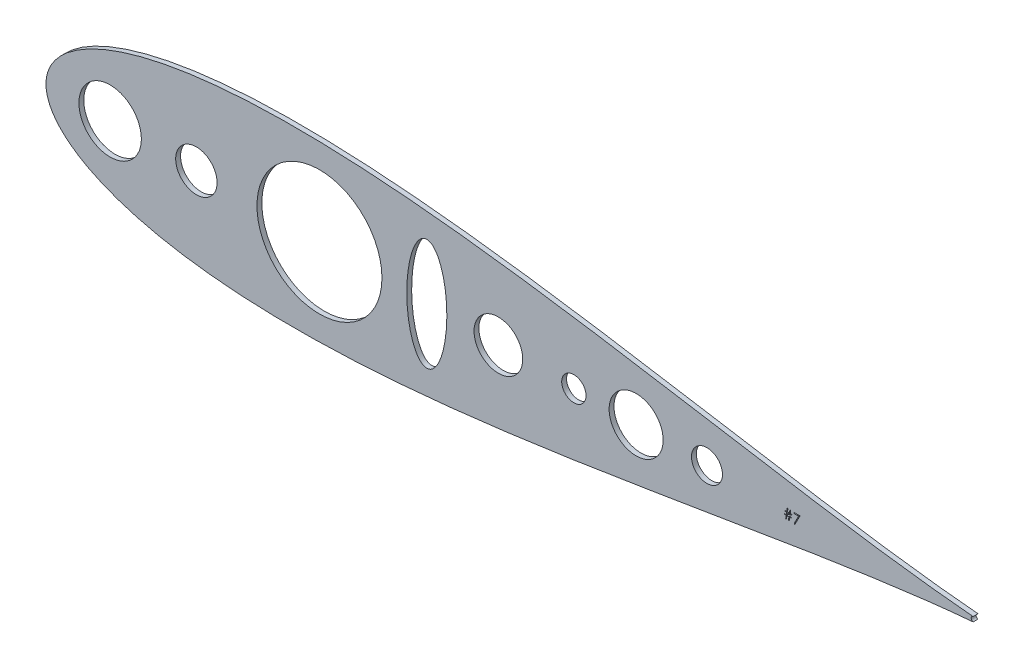
from build123d import *

# Parameters (mm, degrees)
SKETCH2_R           = 16.284851911
SKETCH2_R_2         = 8.086464582
SKETCH2_R_3         = 14.095693802
SKETCH2_R_4         = 6.35
SKETCH2_R_5         = 12.7
SKETCH2_R_6         = 32.589606416
SKETCH2_R_7         = 10.795
SKETCH2_RX          = 29.101247041
SKETCH2_RY          = 10.44471683
BOSS_EXTRUDE1_DEPTH = 2.54


with BuildPart() as part:
    # Sketch2 → Boss-Extrude1 (new body)
    with BuildSketch(Plane.XY):
        with BuildLine():
            ThreePointArc((405.057409883, 1.219307274), (404.060332019, 0.001097472), (405.054413981, -1.219558271))
            add(Edge.make_bspline(
                [(405.057409883, 1.219307274), (404.779756403, 1.242568099), (401.955826011, 1.481310599), (396.284184548, 2.00552928), (387.700215517, 2.898488012), (378.182946349, 3.994235028), (367.768153654, 5.299339088), (356.504426933, 6.815129022), (344.440475863, 8.538206481), (331.628541709, 10.45967103), (318.123030174, 12.56585373), (303.980521449, 14.837949085), (289.259460847, 17.252489472), (274.019988904, 19.781638356), (258.323746519, 22.393472599), (242.233771661, 25.052554066), (225.814395691, 27.720355074), (209.13118913, 30.355889946), (192.250926116, 32.91626741), (175.241581744, 35.357451938), (158.172324108, 37.634822456), (141.113531081, 39.703967669), (124.136802012, 41.521324365), (107.314968663, 43.044946686), (90.722088255, 44.235118014), (74.433442027, 45.055093643), (58.525518859, 45.471792128), (43.075989256, 45.45632188), (28.163731472, 44.984141559), (13.868832743, 44.036763855), (0.27282201, 42.600450864), (-12.541200968, 40.668728208), (-24.48778885, 38.240918261), (-35.478566578, 35.325144932), (-45.42061789, 31.938496856), (-54.214761136, 28.111149637), (-61.754202147, 23.893785873), (-67.926305087, 19.371988319), (-72.627138784, 14.69344535), (-75.809678334, 10.105526882), (-77.58435108, 5.966312248), (-78.30099748, 2.645888854), (-78.464220154, 3e-09), (-78.30099748, -2.645888848), (-77.58435108, -5.966312241), (-75.809678334, -10.105526876), (-72.627138784, -14.693445344), (-67.926305087, -19.371988313), (-61.754202147, -23.893785867), (-54.214761136, -28.11114963), (-45.42061789, -31.938496849), (-35.478566578, -35.325144925), (-24.48778885, -38.240918255), (-12.541200968, -40.668728202), (0.27282201, -42.600450858), (13.868832743, -44.036763849), (28.163731472, -44.984141553), (43.075989256, -45.456321874), (58.525518859, -45.471792122), (74.433442027, -45.055093637), (90.722088255, -44.235118008), (107.314968663, -43.04494668), (124.136802012, -41.521324359), (141.113531081, -39.703967663), (158.172324108, -37.63482245), (175.241581744, -35.357451932), (192.250926116, -32.916267404), (209.13118913, -30.35588994), (225.814395691, -27.720355067), (242.233771661, -25.05255406), (258.323746519, -22.393472593), (274.019988904, -19.78163835), (289.259460847, -17.252489465), (303.980521449, -14.837949079), (318.123030174, -12.565853724), (331.628541709, -10.459671024), (344.440475863, -8.538206474), (356.504426933, -6.815129016), (367.768153654, -5.299339082), (378.182946349, -3.994235021), (387.700215517, -2.898488006), (396.284184548, -2.005529273), (401.954832786, -1.481402395), (404.777759589, -1.242736911), (405.054413981, -1.219558271)],
                knots=[0.020477074, 0.020477074, 0.020477074, 0.020477074, 0.021270888, 0.028552555, 0.036780684, 0.045920102, 0.055931764, 0.066772884, 0.07839713, 0.090754827, 0.103793165, 0.117456432, 0.131686226, 0.146421738, 0.161599998, 0.177156133, 0.193023668, 0.209134786, 0.225420633, 0.241811602, 0.258237647, 0.274628557, 0.290914287, 0.307025229, 0.322892517, 0.338448342, 0.353626207, 0.368361232, 0.382590428, 0.396252961, 0.409290412, 0.42164701, 0.433269881, 0.444109249, 0.45411864, 0.463255055, 0.471479114, 0.478755289, 0.485052318, 0.490344026, 0.494609833, 0.497833231, 0.5, 0.502166769, 0.505390167, 0.509655974, 0.514947682, 0.521244711, 0.528520886, 0.536744945, 0.54588136, 0.555890751, 0.566730119, 0.57835299, 0.590709588, 0.603747039, 0.617409572, 0.631638768, 0.646373793, 0.661551658, 0.677107483, 0.692974771, 0.709085713, 0.725371443, 0.741762353, 0.758188398, 0.774579367, 0.790865214, 0.806976332, 0.822843867, 0.838400002, 0.853578262, 0.868313774, 0.882543568, 0.896206835, 0.909245173, 0.92160287, 0.933227116, 0.944068236, 0.954079898, 0.963219316, 0.971447445, 0.978729112, 0.979520071, 0.979520071, 0.979520071, 0.979520071], degree=3))
        make_face()
        with Locations((-44.975775469, 0)):
            Circle(SKETCH2_R, mode=Mode.SUBTRACT)
        with Locations((266.265845268, 0)):
            Circle(SKETCH2_R_2, mode=Mode.SUBTRACT)
        with Locations((229.326509129, 0)):
            Circle(SKETCH2_R_3, mode=Mode.SUBTRACT)
        with Locations((196.85, 0)):
            Circle(SKETCH2_R_4, mode=Mode.SUBTRACT)
        with Locations((157.48, 0)):
            Circle(SKETCH2_R_5, mode=Mode.SUBTRACT)
        with Locations((64.185947574, 0)):
            Circle(SKETCH2_R_6, mode=Mode.SUBTRACT)
        Circle(SKETCH2_R_7, mode=Mode.SUBTRACT)
        with Locations(Location((120.170920999, 0), (0, 0, -90))):
            Ellipse(SKETCH2_RX, SKETCH2_RY, mode=Mode.SUBTRACT)
        Polygon((310.369258356, -1.459777969), (310.369258356, -1.785418996), (309.398441044, -1.785418996), (309.134875343, -3.543880534), (308.74105323, -3.543880534), (309.004618931, -1.785418996), (307.965620532, -1.785418996), (307.702054831, -3.543880534), (307.308232718, -3.543880534), (307.571798419, -1.785418996), (306.722078869, -1.785418996), (306.722078869, -1.459777969), (307.62064457, -1.459777969), (307.796694245, -0.287470281), (306.85233527, -0.287470281), (306.85233527, 0.038170745), (307.845540398, 0.038170745), (308.089771162, 1.666375871), (308.482575649, 1.666375871), (308.238344886, 0.038170745), (309.278360911, 0.038170745), (309.522591675, 1.666375871), (309.915396162, 1.666375871), (309.671165398, 0.038170745), (310.499514758, 0.038170745), (310.499514758, -0.287470281), (309.622319245, -0.287470281), (309.447287195, -1.459777969), align=None, mode=Mode.SUBTRACT)
        Polygon((311.671822456, 1.536119468), (314.797976296, 1.536119468), (312.127719894, -3.674136944), (311.73389777, -3.457382143), (314.02661412, 1.015093819), (311.671822456, 1.015093819), align=None, mode=Mode.SUBTRACT)
    extrude(amount=BOSS_EXTRUDE1_DEPTH)


solid = part.part
